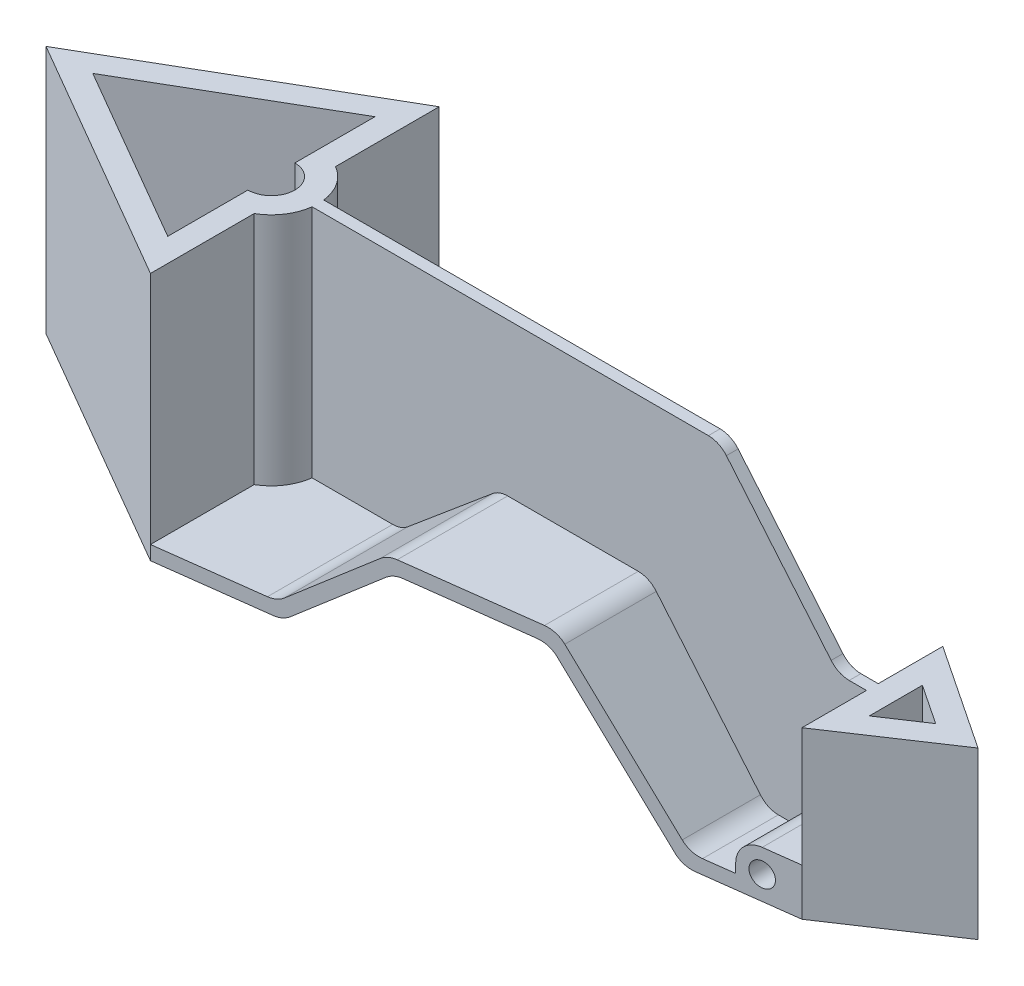
from build123d import *

# Parameters (mm, degrees)
BOSS_EXTRUDE1_DEPTH     = 106
SKETCH3_R               = 5
BOSS_EXTRUDE2_DEPTH     = 61.5
BOSS_EXTRUDE3_START     = -25
BOSS_EXTRUDE3_DEPTH     = 70.666666667
BOSS_EXTRUDE4_DEPTH     = 2.5
FILLET2_R               = 10
CUT_EXTRUDE1_DEPTH      = 107
CUT_EXTRUDE1_DEPTH_BACK = 26
SKETCH7_R               = 20
SKETCH7_R_2             = 10
BOSS_EXTRUDE5_DEPTH     = 106
CUT_EXTRUDE2_DEPTH      = 1
CUT_EXTRUDE2_DEPTH_BACK = 132


with BuildPart() as part:
    # Sketch2 → Boss-Extrude1 (new body)
    with BuildSketch(Plane(origin=(0, 0, 0), x_dir=(1, 0, 0), z_dir=(0, 1, 0))):
        Polygon((0, -61.5), (0, 61.5), (-106, 0), align=None)
        Polygon((-10, 44.136889641), (-86.073338243, 0), (-10, -44.136889641), align=None, mode=Mode.SUBTRACT)
    extrude(amount=BOSS_EXTRUDE1_DEPTH)

    # Sketch3 → Boss-Extrude2 (add, symmetric)
    with BuildSketch(Plane.XY):
        with BuildLine():
            Line((0, 0), (50, 0))
            Line((50, 0), (91.711375741, 35))
            Line((91.711375741, 35), (150.654022129, 35))
            Line((150.654022129, 35), (201, -25))
            Line((201, -25), (246, -25))
            Line((246, -25), (246, -19))
            Line((246, -19), (246, -5))
            Line((246, -5), (231, -5))
            ThreePointArc((231, -5), (223.928932188, -7.928932188), (221, -15))
            Line((221, -15), (221, -19))
            Line((221, -19), (203.797845949, -19))
            Line((203.797845949, -19), (153.451868078, 41))
            Line((153.451868078, 41), (89.527554335, 41))
            Line((89.527554335, 41), (47.816178594, 6))
            Line((47.816178594, 6), (0, 6))
            Line((0, 6), (0, 0))
        make_face()
        with Locations((231, -15)):
            Circle(SKETCH3_R, mode=Mode.SUBTRACT)
    extrude(amount=BOSS_EXTRUDE2_DEPTH, both=True)

    # Sketch4 → Boss-Extrude3 (add)
    with BuildSketch(Plane(origin=(0, 0, 0), x_dir=(1, 0, 0), z_dir=(0, 1, 0)).offset(BOSS_EXTRUDE3_START)):
        Polygon((246, -30), (246, 30), (291, 0), align=None)
        Polygon((256, 11.314829082), (272.972243623, 0), (256, -11.314829082), align=None, mode=Mode.SUBTRACT)
    extrude(amount=BOSS_EXTRUDE3_DEPTH)

    # Sketch5 → Boss-Extrude4 (add, symmetric)
    with BuildSketch(Plane.XY):
        with BuildLine():
            Line((0, 106), (183.326730095, 106))
            Line((183.326730095, 106), (233.952407843, 45.666666667))
            Line((233.952407843, 45.666666667), (246, 45.666666667))
            Line((246, 45.666666667), (246, -5))
            Line((246, -5), (231, -5))
            ThreePointArc((231, -5), (223.928932188, -7.928932188), (221, -15))
            Line((221, -15), (221, -19))
            Line((221, -19), (203.797845949, -19))
            Line((203.797845949, -19), (153.451868078, 41))
            Line((153.451868078, 41), (89.527554335, 41))
            Line((89.527554335, 41), (47.816178594, 6))
            Line((47.816178594, 6), (0, 6))
            Line((0, 6), (0, 106))
        make_face()
    extrude(amount=BOSS_EXTRUDE4_DEPTH, both=True)

    # Fillet2
    fillet2_edges = [part.edges().sort_by_distance(p)[0] for p in [
        (50, 0, 0),
        (91.711375741, 35, 0),
        (150.654022129, 35, 0),
        (201, -25, 0),
        (203.797845949, -19, 32),
        (153.451868078, 41, 32),
        (89.527554335, 41, 32),
        (47.816178594, 6, 32),
        (47.816178594, 6, -32),
        (89.527554335, 41, -32),
        (153.451868078, 41, -32),
        (203.797845949, -19, -32),
        (233.952407843, 45.666666667, 0),
        (183.326730095, 106, 0),
    ]]
    fillet(fillet2_edges, radius=FILLET2_R)

    # Sketch6 → Cut-Extrude1 (cut, two sides)
    with BuildSketch(Plane(origin=(0, 0, 0), x_dir=(1, 0, 0), z_dir=(0, 1, 0))) as cut_extrude1_sk:
        Polygon((0, 61.5), (246, 61.5), (246, 30), align=None)
        Polygon((0, -61.5), (246, -30), (246, -61.5), align=None)
    extrude(amount=CUT_EXTRUDE1_DEPTH, mode=Mode.SUBTRACT)
    extrude(cut_extrude1_sk.sketch, amount=-CUT_EXTRUDE1_DEPTH_BACK, mode=Mode.SUBTRACT)

    # Sketch7 → Boss-Extrude5 (add)
    with BuildSketch(Plane(origin=(0, 0, 0), x_dir=(1, 0, 0), z_dir=(0, 1, 0))):
        with Locations((-10, 0)):
            Circle(SKETCH7_R)
        with Locations((-10, 0)):
            Circle(SKETCH7_R_2, mode=Mode.SUBTRACT)
    extrude(amount=BOSS_EXTRUDE5_DEPTH)

    # Sketch8 → Cut-Extrude2 (cut, two sides)
    with BuildSketch(Plane(origin=(0, 106, 0), x_dir=(1, 0, 0), z_dir=(0, 1, 0))) as cut_extrude2_sk:
        with BuildLine():
            Line((-86.073338243, 0), (-10, 44.136889641))
            Line((-10, 44.136889641), (-10, 10))
            ThreePointArc((-10, 10), (0, 0), (-10, -10))
            Line((-10, -10), (-10, -44.136889641))
            Line((-10, -44.136889641), (-86.073338243, 0))
        make_face()
    extrude(amount=CUT_EXTRUDE2_DEPTH, mode=Mode.SUBTRACT)
    extrude(cut_extrude2_sk.sketch, amount=-CUT_EXTRUDE2_DEPTH_BACK, mode=Mode.SUBTRACT)


solid = part.part
